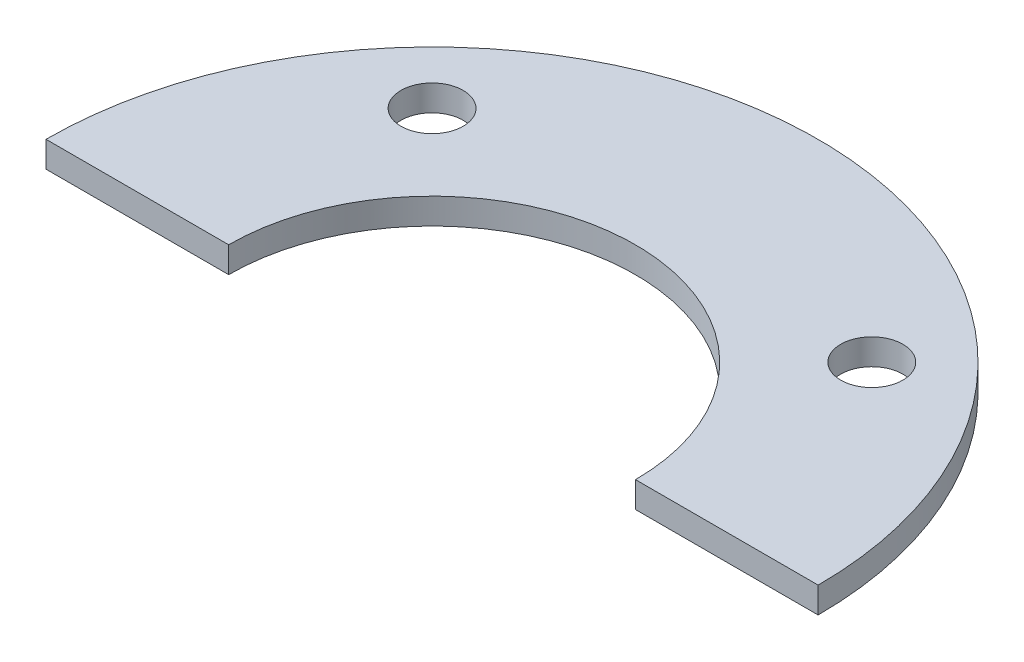
from build123d import *

# Parameters (mm, degrees)
BOSS_EXTRUDE1_DEPTH = 1.27
SKETCH2_R           = 1.524
CUT_EXTRUDE1_DEPTH  = 2.27


with BuildPart() as part:
    # Sketch1 → Boss-Extrude1 (new body)
    with BuildSketch(Plane(origin=(0, 0, 0), x_dir=(1, 0, 0), z_dir=(0, 1, 0))):
        with BuildLine():
            Line((-9.9695, 0), (-18.923, 0))
            ThreePointArc((-18.923, 0), (0, 18.923), (18.923, 0))
            Line((18.923, 0), (9.9695, 0))
            ThreePointArc((9.9695, 0), (0, 9.9695), (-9.9695, 0))
        make_face()
    extrude(amount=BOSS_EXTRUDE1_DEPTH)

    # Sketch2 → Cut-Extrude1 (cut, through all)
    with BuildSketch(Plane(origin=(0, 1.27, 0), x_dir=(1, 0, 0), z_dir=(0, 1, 0))):
        with Locations((-10.776307345, 10.776307345)):
            Circle(SKETCH2_R)
        with Locations((10.776307345, 10.776307345)):
            Circle(SKETCH2_R)
    extrude(amount=-CUT_EXTRUDE1_DEPTH, mode=Mode.SUBTRACT)


solid = part.part
